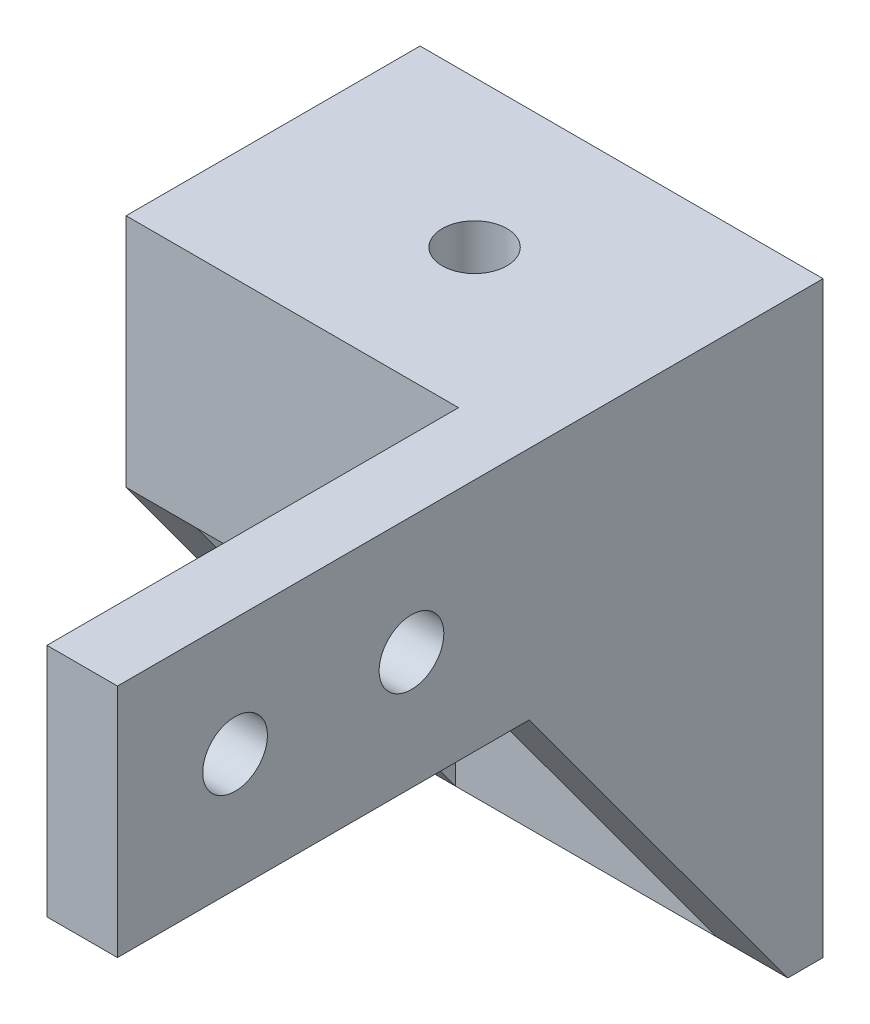
from build123d import *

# Parameters (mm, degrees)
SKETCH1_W           = 17.135
SKETCH1_H           = 12.5
BASE_DEPTH          = 5
SKETCH2_W           = 17.135
SKETCH2_H           = 15
BOSS_EXTRUDE2_DEPTH = 1.5
BOSS_EXTRUDE3_DEPTH = 17.135
SKETCH4_W           = 11.135
SKETCH4_H           = 15
CUT_EXTRUDE1_DEPTH  = 11
SKETCH5_R           = 1.375
CUT_EXTRUDE2_DEPTH  = 2
SKETCH6_R           = 1.375
CUT_EXTRUDE3_DEPTH  = 5.75
SKETCH7_W           = 17.135
SKETCH7_H           = 12.5
SKETCH7_R           = 1.375
BOSS_EXTRUDE4_DEPTH = 5
SKETCH8_W           = 17.5
SKETCH8_H           = 10
SKETCH8_R           = 1.375
BOSS_EXTRUDE5_DEPTH = 3


with BuildPart() as part:
    # Sketch1 → base (new body)
    with BuildSketch(Plane(origin=(0, 0, 0), x_dir=(1, 0, 0), z_dir=(0, 1, 0))):
        with Locations((8.5675, 6.25)):
            Rectangle(SKETCH1_W, SKETCH1_H)
    extrude(amount=BASE_DEPTH)

    # Sketch2 → Boss-Extrude2 (add)
    with BuildSketch(Plane(origin=(0, 0, -12.5), x_dir=(-1, 0, 0), z_dir=(0, 0, -1))):
        with Locations((-8.5675, -7.5)):
            Rectangle(SKETCH2_W, SKETCH2_H)
    extrude(amount=-BOSS_EXTRUDE2_DEPTH)

    # Sketch3 → Boss-Extrude3 (add)
    with BuildSketch(Plane.ZY):
        Polygon((0, 0), (-11, -15), (-11, 0), align=None)
    extrude(amount=-BOSS_EXTRUDE3_DEPTH)

    # Sketch4 → Cut-Extrude1 (cut)
    with BuildSketch(Plane.XY):
        with Locations((8.5675, -7.5)):
            Rectangle(SKETCH4_W, SKETCH4_H)
    extrude(amount=-CUT_EXTRUDE1_DEPTH, mode=Mode.SUBTRACT)

    # Sketch5 → Cut-Extrude2 (cut)
    with BuildSketch(Plane.XY.offset(-11)):
        with Locations((8.5675, -4)):
            Circle(SKETCH5_R)
        with Locations((8.5675, -11)):
            Circle(SKETCH5_R)
    extrude(amount=-CUT_EXTRUDE2_DEPTH, mode=Mode.SUBTRACT)

    # Sketch6 → Cut-Extrude3 (cut)
    with BuildSketch(Plane(origin=(0, 5, 0), x_dir=(1, 0, 0), z_dir=(0, 1, 0))):
        with Locations((8.5675, 6.25)):
            Circle(SKETCH6_R)
    extrude(amount=-CUT_EXTRUDE3_DEPTH, mode=Mode.SUBTRACT)

    # Sketch7 → Boss-Extrude4 (add)
    with BuildSketch(Plane(origin=(0, 5, 0), x_dir=(1, 0, 0), z_dir=(0, 1, 0))):
        with Locations((8.5675, 6.25)):
            Rectangle(SKETCH7_W, SKETCH7_H)
        with Locations((8.5675, 6.25)):
            Circle(SKETCH7_R, mode=Mode.SUBTRACT)
    extrude(amount=BOSS_EXTRUDE4_DEPTH)

    # Sketch8 → Boss-Extrude5 (add)
    with BuildSketch(Plane(origin=(17.135, 0, 0), x_dir=(0, 0, -1), z_dir=(1, 0, 0))):
        with Locations((-8.75, 5)):
            Rectangle(SKETCH8_W, SKETCH8_H)
        with Locations((-5, 5)):
            Circle(SKETCH8_R, mode=Mode.SUBTRACT)
        with Locations((-12.5, 5)):
            Circle(SKETCH8_R, mode=Mode.SUBTRACT)
    extrude(amount=-BOSS_EXTRUDE5_DEPTH)


solid = part.part
